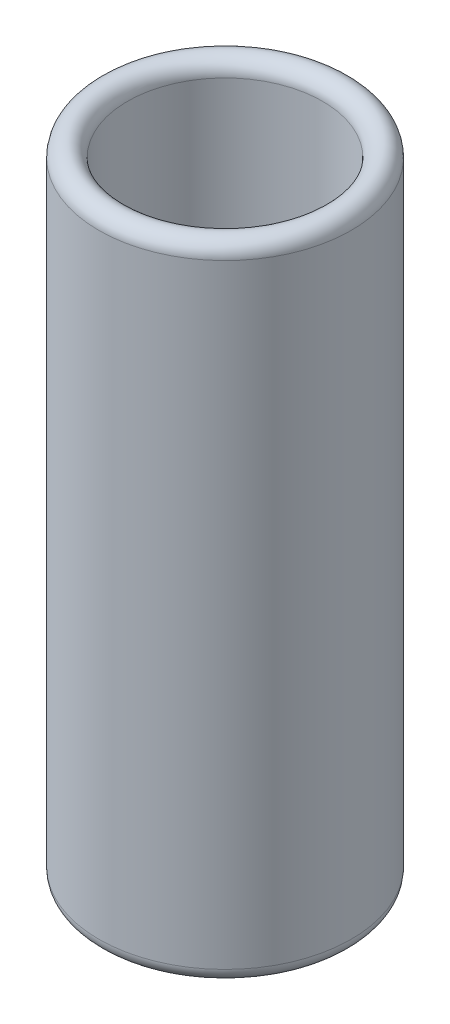
from build123d import *


with BuildPart() as part:
    # Esquisse1 → Révolution1 (revolve)
    with BuildSketch(Plane.XY, mode=Mode.PRIVATE) as r_volution1_sk:
        with BuildLine():
            Line((3.4, 21.4), (3.4, 0))
            ThreePointArc((3.4, 0), (3.9, -0.5), (4.4, 0))
            Line((4.4, 0), (4.4, 21.4))
            ThreePointArc((4.4, 21.4), (3.9, 21.9), (3.4, 21.4))
        make_face()
    revolve(r_volution1_sk.sketch.rotate(Axis((0, 23.03099143, 0), (0, -1, 0)), 90), axis=Axis((0, 23.03099143, 0), (0, -1, 0)))  # turned: the seam where the file's is


solid = part.part
